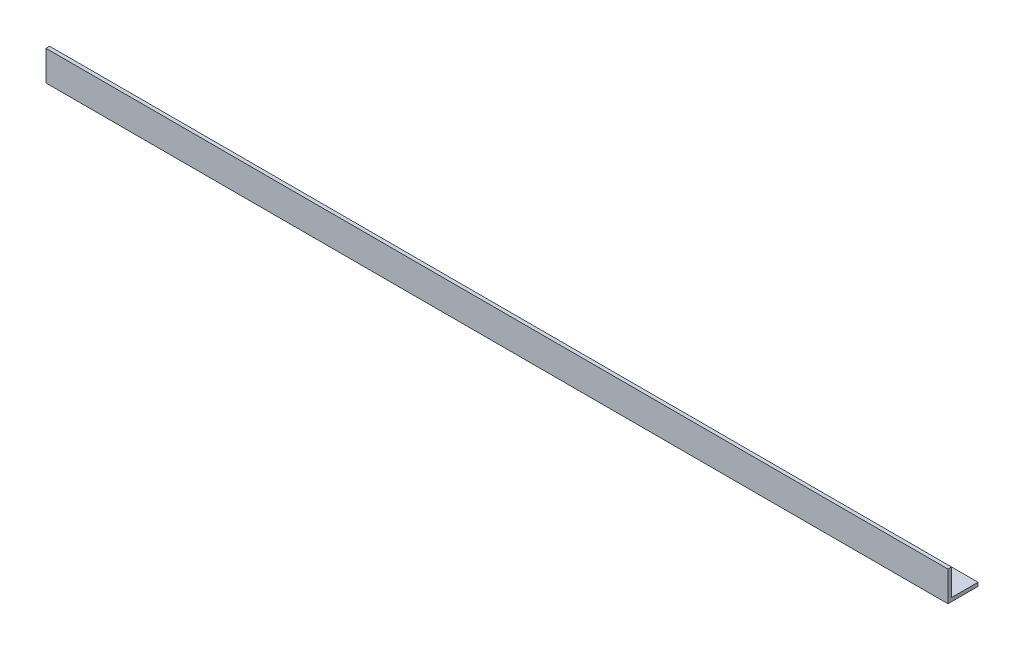
from build123d import *

# Parameters (mm, degrees)
EXTRUDE_2_DEPTH = 1500


with BuildPart() as part:
    # Эскиз1 → Вытянуть-Тонкостенный2 (new body)
    with BuildSketch(Plane(origin=(0, 0, 0), x_dir=(0, 0, -1), z_dir=(1, 0, 0))):
        Polygon((0, 50), (0, 0), (50, 0), (50, 6), (6, 6), (6, 50), align=None)
    extrude(amount=EXTRUDE_2_DEPTH)


solid = part.part
